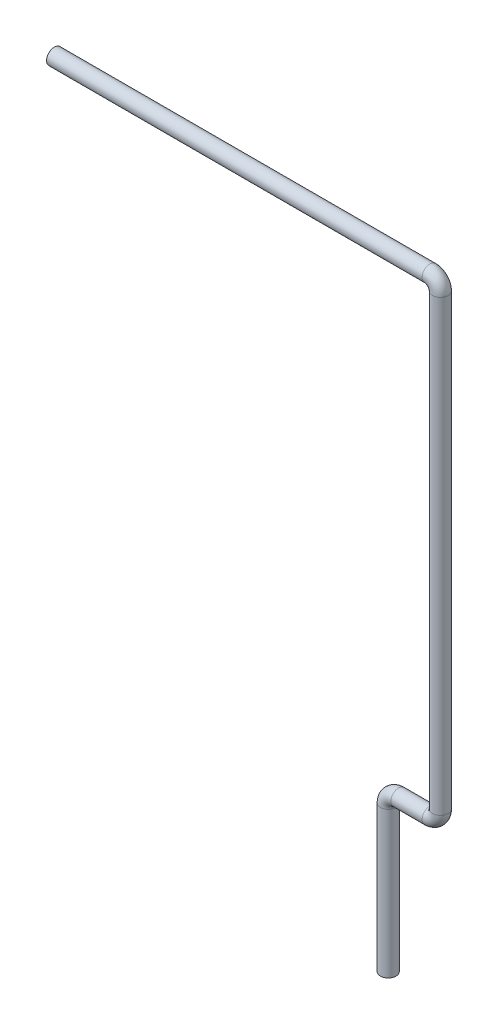
from build123d import *

# Parameters (mm, degrees)
SKETCH2_R          = 7.5
SKETCH2_R_2        = 6
SKETCH3_R          = 2.5
CUT_EXTRUDE1_DEPTH = 10


with BuildPart() as part:
    # Sweep-Thin1: sweep along a path in Sketch1
    with BuildLine(Plane.XY) as sweep_thin1_path:
        Line((0, 0), (360, 0))
        ThreePointArc((360, 0), (367.071067812, -2.928932188), (370, -10))
        Line((370, -10), (370, -440))
        ThreePointArc((370, -440), (367.071067812, -447.071067812), (360, -450))
        Line((360, -450), (330, -450))
        ThreePointArc((330, -450), (322.928932188, -452.928932188), (320, -460))
        Line((320, -460), (320, -600))
    # Sketch2 → Sweep-Thin1 (sweep)
    with BuildSketch(Plane(origin=(0, 0, 0), x_dir=(0, 0, -1), z_dir=(1, 0, 0))):
        Circle(SKETCH2_R)
        Circle(SKETCH2_R_2, mode=Mode.SUBTRACT)
    sweep(path=sweep_thin1_path.line)

    # Sketch3 → Cut-Extrude1 (cut)
    with BuildSketch(Plane(origin=(0, 0, 0), x_dir=(1, 0, 0), z_dir=(0, 1, 0))):
        with Locations((19.113136716, 0)):
            Circle(SKETCH3_R)
        with Locations((39.113136716, 0)):
            Circle(SKETCH3_R)
        with Locations((59.113136716, 0)):
            Circle(SKETCH3_R)
        with Locations((79.113136716, 0)):
            Circle(SKETCH3_R)
        with Locations((99.113136716, 0)):
            Circle(SKETCH3_R)
        with Locations((119.113136716, 0)):
            Circle(SKETCH3_R)
        with Locations((139.113136716, 0)):
            Circle(SKETCH3_R)
        with Locations((159.113136716, 0)):
            Circle(SKETCH3_R)
        with Locations((179.113136716, 0)):
            Circle(SKETCH3_R)
        with Locations((199.113136716, 0)):
            Circle(SKETCH3_R)
        with Locations((219.113136716, 0)):
            Circle(SKETCH3_R)
        with Locations((239.113136716, 0)):
            Circle(SKETCH3_R)
        with Locations((259.113136716, 0)):
            Circle(SKETCH3_R)
        with Locations((279.113136716, 0)):
            Circle(SKETCH3_R)
        with Locations((299.113136716, 0)):
            Circle(SKETCH3_R)
        with Locations((319.113136716, 0)):
            Circle(SKETCH3_R)
        with Locations((339.113136716, 0)):
            Circle(SKETCH3_R)
    extrude(amount=-CUT_EXTRUDE1_DEPTH, mode=Mode.SUBTRACT)


solid = part.part
